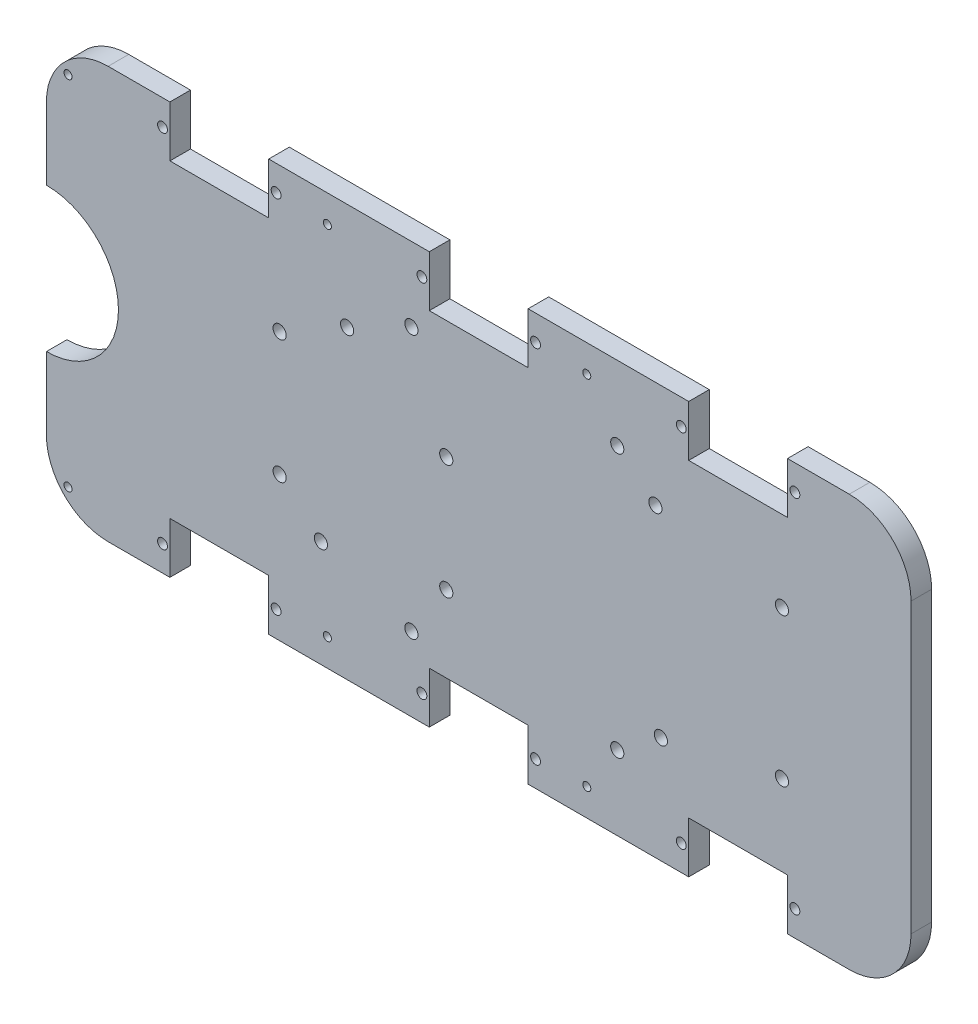
from build123d import *

# Parameters (mm, degrees)
BOSS_EXTRUDE2_DEPTH = 5
SKETCH2_W           = 24
SKETCH2_H           = 12.4
CUT_EXTRUDE1_DEPTH  = 5
SKETCH3_R           = 1.2
CUT_EXTRUDE2_DEPTH  = 5
SKETCH5_R           = 0.975
CUT_EXTRUDE3_DEPTH  = 10
SKETCH6_R           = 17.5
CUT_EXTRUDE4_DEPTH  = 10
SKETCH8_R           = 1.6
CUT_EXTRUDE5_DEPTH  = 10
BOSS_EXTRUDE3_DEPTH = 17.7
SKETCH12_R          = 1.2
CUT_EXTRUDE6_DEPTH  = 5


with BuildPart() as part:
    # Sketch1 → Boss-Extrude2 (new body)
    with BuildSketch(Plane.XY):
        with BuildLine():
            Line((-90, -50), (90, -50))
            ThreePointArc((90, -50), (100.606601718, -45.606601718), (105, -35))
            Line((105, -35), (105, 35))
            ThreePointArc((105, 35), (100.606601718, 45.606601718), (90, 50))
            Line((90, 50), (-90, 50))
            ThreePointArc((-90, 50), (-100.606601718, 45.606601718), (-105, 35))
            Line((-105, 35), (-105, -35))
            ThreePointArc((-105, -35), (-100.606601718, -45.606601718), (-90, -50))
        make_face()
    extrude(amount=BOSS_EXTRUDE2_DEPTH)

    # Sketch2 → Cut-Extrude1 (cut)
    with BuildSketch(Plane.XY.offset(5)):
        with Locations((63, -43.8)):
            Rectangle(SKETCH2_W, SKETCH2_H)
        with Locations((-63, 43.8)):
            Rectangle(SKETCH2_W, SKETCH2_H)
        with Locations((0, 43.8)):
            Rectangle(SKETCH2_W, SKETCH2_H)
        with Locations((63, 43.8)):
            Rectangle(SKETCH2_W, SKETCH2_H)
        with Locations((0, -43.8)):
            Rectangle(SKETCH2_W, SKETCH2_H)
        with Locations((-63, -43.8)):
            Rectangle(SKETCH2_W, SKETCH2_H)
    extrude(amount=-CUT_EXTRUDE1_DEPTH, mode=Mode.SUBTRACT)

    # Sketch3 → Cut-Extrude2 (cut)
    with BuildSketch(Plane.XY.offset(5)):
        with Locations((-76.8, 43.8)):
            Circle(SKETCH3_R)
        with Locations((-49.2, 43.8)):
            Circle(SKETCH3_R)
        with Locations((-13.8, 43.8)):
            Circle(SKETCH3_R)
        with Locations((13.8, 43.8)):
            Circle(SKETCH3_R)
        with Locations((49.2, 43.8)):
            Circle(SKETCH3_R)
        with Locations((76.8, 43.8)):
            Circle(SKETCH3_R)
        with Locations((-76.8, -43.8)):
            Circle(SKETCH3_R)
        with Locations((-49.2, -43.8)):
            Circle(SKETCH3_R)
        with Locations((-13.8, -43.8)):
            Circle(SKETCH3_R)
        with Locations((13.8, -43.8)):
            Circle(SKETCH3_R)
        with Locations((49.2, -43.8)):
            Circle(SKETCH3_R)
        with Locations((76.8, -43.8)):
            Circle(SKETCH3_R)
    extrude(amount=-CUT_EXTRUDE2_DEPTH, mode=Mode.SUBTRACT)

    # Sketch5 → Cut-Extrude3 (cut)
    with BuildSketch(Plane.XY.offset(5)):
        with Locations((-36.75, 43.360200931)):
            Circle(SKETCH5_R)
        with Locations((26.25, 43.360200931)):
            Circle(SKETCH5_R)
        with Locations((26.25, -43.360200931)):
            Circle(SKETCH5_R)
        with Locations((-36.75, -43.360200931)):
            Circle(SKETCH5_R)
        with Locations((-99.75, 43.360200931)):
            Circle(SKETCH5_R)
        with Locations((-99.75, -43.360200931)):
            Circle(SKETCH5_R)
    extrude(amount=-CUT_EXTRUDE3_DEPTH, mode=Mode.SUBTRACT)

    # Sketch6 → Cut-Extrude4 (cut)
    with BuildSketch(Plane.XY.offset(5)):
        with Locations((-105, 0)):
            Circle(SKETCH6_R)
    extrude(amount=-CUT_EXTRUDE4_DEPTH, mode=Mode.SUBTRACT)

    # Sketch8 → Cut-Extrude5 (cut)
    with BuildSketch(Plane(origin=(0, 0, 0), x_dir=(-1, 0, 0), z_dir=(0, 0, -1))):
        with Locations((31.97, 24.11)):
            Circle(SKETCH8_R)
        with Locations((38.33, -24.11)):
            Circle(SKETCH8_R)
        with Locations((7.88, 8.88)):
            Circle(SKETCH8_R)
        with Locations((7.88, -19.03)):
            Circle(SKETCH8_R)
        with Locations((-42.91, 24.11)):
            Circle(SKETCH8_R)
        with Locations((-44.24, -24.11)):
            Circle(SKETCH8_R)
        with Locations((-73.65, 18)):
            Circle(SKETCH8_R)
        with Locations((48.35, 15)):
            Circle(SKETCH8_R)
        with Locations((-73.65, -18)):
            Circle(SKETCH8_R)
        with Locations((48.35, -15)):
            Circle(SKETCH8_R)
        with Locations((-33.65, 32)):
            Circle(SKETCH8_R)
        with Locations((16.35, 32)):
            Circle(SKETCH8_R)
        with Locations((-33.65, -32)):
            Circle(SKETCH8_R)
        with Locations((16.35, -32)):
            Circle(SKETCH8_R)
    extrude(amount=-CUT_EXTRUDE5_DEPTH, mode=Mode.SUBTRACT)

    # Sketch10 → Boss-Extrude3 (add)
    with BuildSketch(Plane(origin=(0, 0, 0), x_dir=(-1, 0, 0), z_dir=(0, 0, -1))):
        Polygon((71.290147782, 0), (71.290147782, -11.5), (58.890147782, -11.5), (58.890147782, 11.5), (71.290147782, 11.5), (71.290147782, 16.5), (53.890147782, 16.5), (53.890147782, -16.5), (76.290147782, -16.5), (76.290147782, 0), align=None)
    extrude(amount=BOSS_EXTRUDE3_DEPTH)

    # Sketch12 → Cut-Extrude6 (cut)
    with BuildSketch(Plane(origin=(0, 0, -17.7), x_dir=(-1, 0, 0), z_dir=(0, 0, -1))):
        with Locations((65.090147782, -13.8)):
            Circle(SKETCH12_R)
        with Locations((65.090147782, 13.8)):
            Circle(SKETCH12_R)
    extrude(amount=-CUT_EXTRUDE6_DEPTH, mode=Mode.SUBTRACT)


solid = part.part
